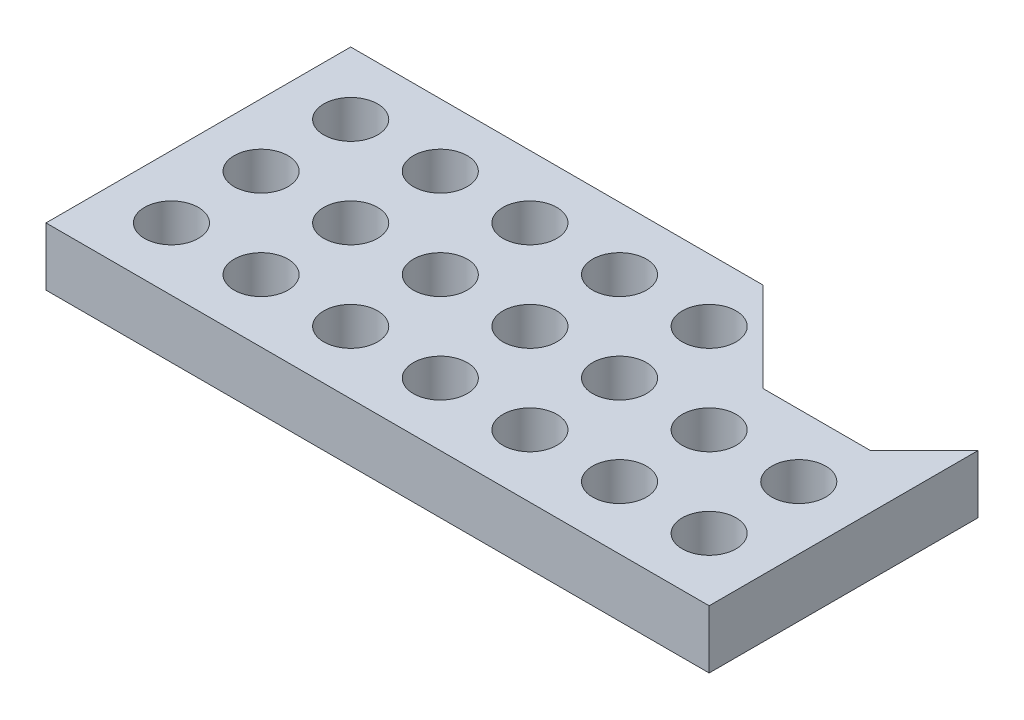
from build123d import *

# Parameters (mm, degrees)
SKETCH1_R           = 1.5025
BOSS_EXTRUDE1_DEPTH = 3.25


with BuildPart() as part:
    # Sketch1 → Boss-Extrude1 (new body)
    with BuildSketch(Plane(origin=(0, 0, 0), x_dir=(1, 0, 0), z_dir=(0, 1, 0))):
        Polygon((-18.5, 8.5), (4.5, 8.5), (9.5, 3.5), (15.5, 3.5), (18.5, 6.5), (18.5, -8.5), (-18.5, -8.5), align=None)
        with Locations((-15, -5)):
            Circle(SKETCH1_R, mode=Mode.SUBTRACT)
        with Locations((-10, -5)):
            Circle(SKETCH1_R, mode=Mode.SUBTRACT)
        with Locations((-5, -5)):
            Circle(SKETCH1_R, mode=Mode.SUBTRACT)
        with Locations((0, -5)):
            Circle(SKETCH1_R, mode=Mode.SUBTRACT)
        with Locations((5, -5)):
            Circle(SKETCH1_R, mode=Mode.SUBTRACT)
        with Locations((10, -5)):
            Circle(SKETCH1_R, mode=Mode.SUBTRACT)
        with Locations((15, -5)):
            Circle(SKETCH1_R, mode=Mode.SUBTRACT)
        with Locations((-10, 0)):
            Circle(SKETCH1_R, mode=Mode.SUBTRACT)
        with Locations((-5, 0)):
            Circle(SKETCH1_R, mode=Mode.SUBTRACT)
        Circle(SKETCH1_R, mode=Mode.SUBTRACT)
        with Locations((5, 0)):
            Circle(SKETCH1_R, mode=Mode.SUBTRACT)
        with Locations((10, 0)):
            Circle(SKETCH1_R, mode=Mode.SUBTRACT)
        with Locations((15, 0)):
            Circle(SKETCH1_R, mode=Mode.SUBTRACT)
        with Locations((-10, 5)):
            Circle(SKETCH1_R, mode=Mode.SUBTRACT)
        with Locations((-5, 5)):
            Circle(SKETCH1_R, mode=Mode.SUBTRACT)
        with Locations((0, 5)):
            Circle(SKETCH1_R, mode=Mode.SUBTRACT)
        with Locations((5, 5)):
            Circle(SKETCH1_R, mode=Mode.SUBTRACT)
        with Locations((-15, 0)):
            Circle(SKETCH1_R, mode=Mode.SUBTRACT)
        with Locations((-15, 5)):
            Circle(SKETCH1_R, mode=Mode.SUBTRACT)
    extrude(amount=BOSS_EXTRUDE1_DEPTH)


solid = part.part
